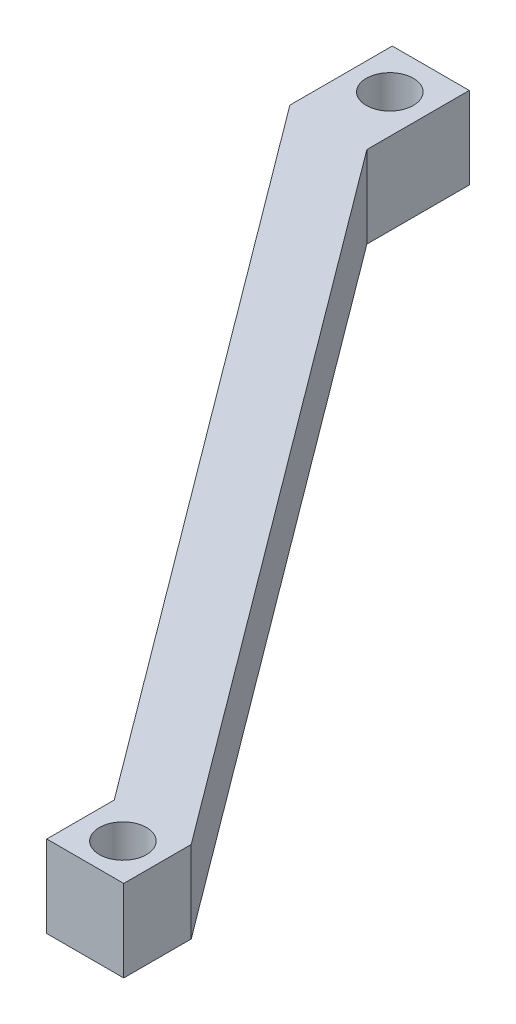
from build123d import *

# Parameters (mm, degrees)
BOSS_EXTRUDE2_DEPTH = 20
SKETCH3_R           = 5.75
CUT_EXTRUDE1_DEPTH  = 21


with BuildPart() as part:
    # Sketch2 → Boss-Extrude2 (new body)
    with BuildSketch(Plane(origin=(0, 0, 0), x_dir=(1, 0, 0), z_dir=(0, 1, 0))):
        Polygon((9.396902384, 10), (9.396902384, -15), (134.887059708, -183.381175952), (134.887059708, -199.855922102), (116.09325494, -199.855922102), (116.09325494, -183.381175952), (-9.396902384, -15), (-9.396902384, 10), align=None)
    extrude(amount=BOSS_EXTRUDE2_DEPTH)

    # Sketch3 → Cut-Extrude1 (cut, through all)
    with BuildSketch(Plane(origin=(0, 20, 0), x_dir=(1, 0, 0), z_dir=(0, 1, 0))):
        Circle(SKETCH3_R)
        with Locations((125.834728431, -190.993349415)):
            Circle(SKETCH3_R)
    extrude(amount=-CUT_EXTRUDE1_DEPTH, mode=Mode.SUBTRACT)


solid = part.part
